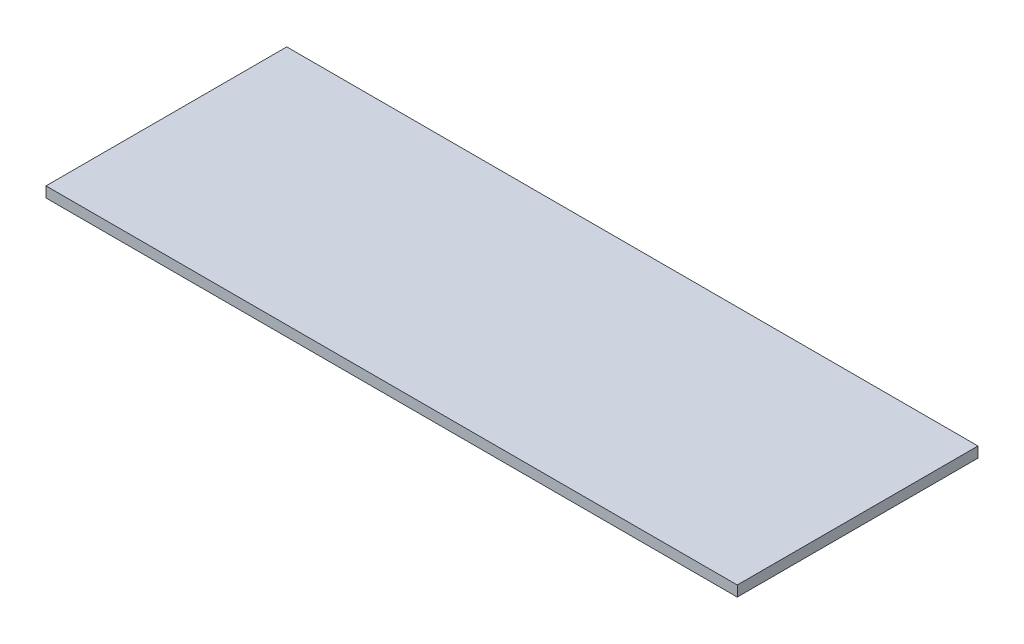
from build123d import *

# Parameters (mm, degrees)
SKETCH1_W           = 269.85
SKETCH1_H           = 93.98
BOSS_EXTRUDE1_DEPTH = 4.11


with BuildPart() as part:
    # Sketch1 → Boss-Extrude1 (new body)
    with BuildSketch(Plane(origin=(0, 0, 0), x_dir=(1, 0, 0), z_dir=(0, 1, 0))):
        Rectangle(SKETCH1_W, SKETCH1_H)
    extrude(amount=BOSS_EXTRUDE1_DEPTH)


solid = part.part
